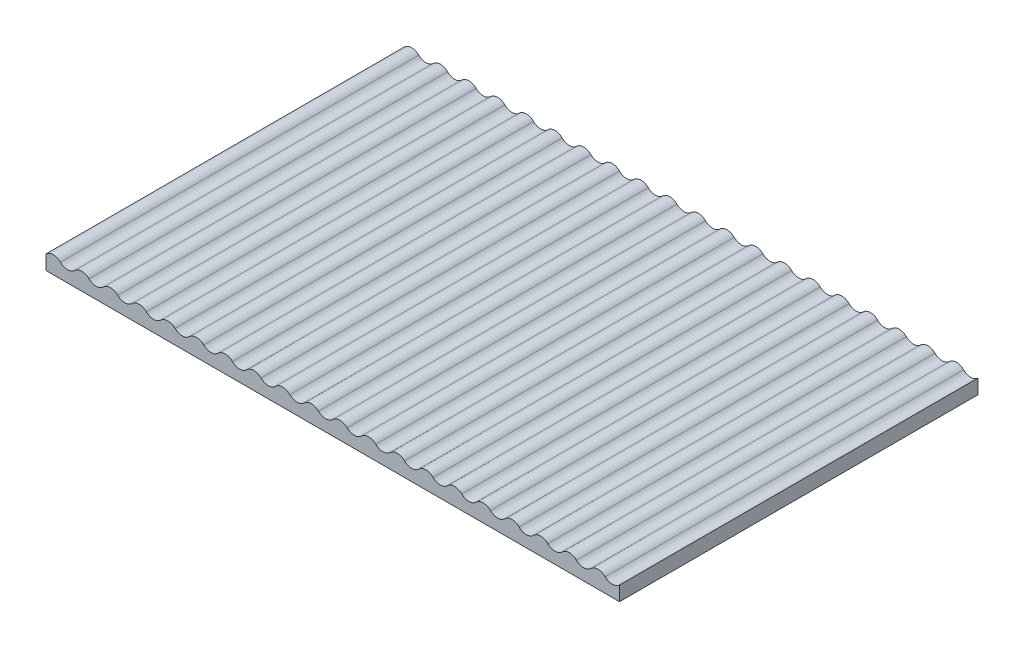
from build123d import *

# Parameters (mm, degrees)
BOSS_EXTRUDE1_DEPTH = 250


with BuildPart() as part:
    # Sketch1 → Boss-Extrude1 (new body)
    with BuildSketch(Plane.XY):
        with BuildLine():
            Line((0, 0.079324087), (0, -10))
            Line((0, -10), (400, -10))
            Line((400, -10), (400, 0.079324087))
            ThreePointArc((400, 0.079324087), (395, -1.974497919), (390, 0.079324087))
            ThreePointArc((390, 0.079324087), (385, 2.133146093), (380, 0.079324087))
            ThreePointArc((380, 0.079324087), (375, -1.974497919), (370, 0.079324087))
            ThreePointArc((370, 0.079324087), (365, 2.133146093), (360, 0.079324087))
            ThreePointArc((360, 0.079324087), (355, -1.974497919), (350, 0.079324087))
            ThreePointArc((350, 0.079324087), (345, 2.133146093), (340, 0.079324087))
            ThreePointArc((340, 0.079324087), (335, -1.974497919), (330, 0.079324087))
            ThreePointArc((330, 0.079324087), (325, 2.133146093), (320, 0.079324087))
            ThreePointArc((320, 0.079324087), (315, -1.974497919), (310, 0.079324087))
            ThreePointArc((310, 0.079324087), (305, 2.133146093), (300, 0.079324087))
            ThreePointArc((300, 0.079324087), (295, -1.974497919), (290, 0.079324087))
            ThreePointArc((290, 0.079324087), (285, 2.133146093), (280, 0.079324087))
            ThreePointArc((280, 0.079324087), (275, -1.974497919), (270, 0.079324087))
            ThreePointArc((270, 0.079324087), (265, 2.133146093), (260, 0.079324087))
            ThreePointArc((260, 0.079324087), (255, -1.974497919), (250, 0.079324087))
            ThreePointArc((250, 0.079324087), (245, 2.133146093), (240, 0.079324087))
            ThreePointArc((240, 0.079324087), (235, -1.974497919), (230, 0.079324087))
            ThreePointArc((230, 0.079324087), (225, 2.133146093), (220, 0.079324087))
            ThreePointArc((220, 0.079324087), (215, -1.974497919), (210, 0.079324087))
            ThreePointArc((210, 0.079324087), (205, 2.133146093), (200, 0.079324087))
            ThreePointArc((200, 0.079324087), (195, -1.974497919), (190, 0.079324087))
            ThreePointArc((190, 0.079324087), (185, 2.133146093), (180, 0.079324087))
            ThreePointArc((180, 0.079324087), (175, -1.974497919), (170, 0.079324087))
            ThreePointArc((170, 0.079324087), (165, 2.133146093), (160, 0.079324087))
            ThreePointArc((160, 0.079324087), (155, -1.974497919), (150, 0.079324087))
            ThreePointArc((150, 0.079324087), (145, 2.133146093), (140, 0.079324087))
            ThreePointArc((140, 0.079324087), (135, -1.974497919), (130, 0.079324087))
            ThreePointArc((130, 0.079324087), (125, 2.133146093), (120, 0.079324087))
            ThreePointArc((120, 0.079324087), (115, -1.974497919), (110, 0.079324087))
            ThreePointArc((110, 0.079324087), (105, 2.133146093), (100, 0.079324087))
            ThreePointArc((100, 0.079324087), (95, -1.974497919), (90, 0.079324087))
            ThreePointArc((90, 0.079324087), (85, 2.133146093), (80, 0.079324087))
            ThreePointArc((80, 0.079324087), (75, -1.974497919), (70, 0.079324087))
            ThreePointArc((70, 0.079324087), (65, 2.133146093), (60, 0.079324087))
            ThreePointArc((60, 0.079324087), (55, -1.974497919), (50, 0.079324087))
            ThreePointArc((50, 0.079324087), (45, 2.133146093), (40, 0.079324087))
            ThreePointArc((40, 0.079324087), (35, -1.974497919), (30, 0.079324087))
            ThreePointArc((30, 0.079324087), (25, 2.133146093), (20, 0.079324087))
            ThreePointArc((20, 0.079324087), (15, -1.974497919), (10, 0.079324087))
            ThreePointArc((10, 0.079324087), (5, 2.133146093), (0, 0.079324087))
        make_face()
    extrude(amount=-BOSS_EXTRUDE1_DEPTH)


solid = part.part
